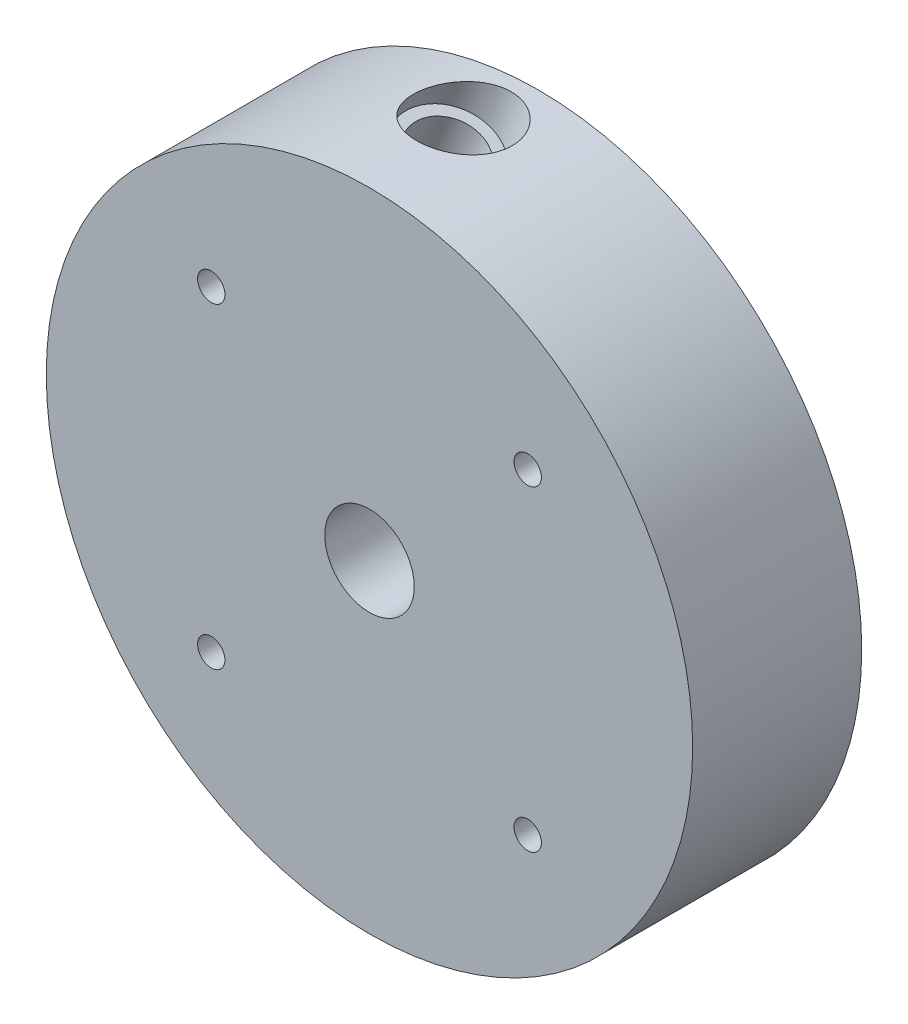
from build123d import *

# Parameters (mm, degrees)
SKETCH3_R          = 65
SKETCH3_R_2        = 2.75
EXTRUDE1_DEPTH     = 34
CUT_EXTRUDE2_DEPTH = 20
SKETCH22_R         = 6.8
CUT_EXTRUDE3_DEPTH = 53.960179098
SKETCH26_R         = 9
CUT_EXTRUDE4_DEPTH = 35.0000001
SKETCH27_R         = 9
CUT_EXTRUDE5_DEPTH = 36.160179098


with BuildPart() as part:
    # Sketch3 → Extrude1 (new body)
    with BuildSketch(Plane.XY):
        Circle(SKETCH3_R)
        with Locations((31.819805153, -31.819805153)):
            Circle(SKETCH3_R_2, mode=Mode.SUBTRACT)
        with Locations((-31.819805153, -31.819805153)):
            Circle(SKETCH3_R_2, mode=Mode.SUBTRACT)
        with Locations((31.819805153, 31.819805153)):
            Circle(SKETCH3_R_2, mode=Mode.SUBTRACT)
        with Locations((-31.819805153, 31.819805153)):
            Circle(SKETCH3_R_2, mode=Mode.SUBTRACT)
    extrude(amount=EXTRUDE1_DEPTH)

    # Sketch3_6 → Cut-Extrude2 (cut)
    with BuildSketch(Plane.XY):
        with BuildLine():
            Line((-20.421328258, 43.144950309), (-27.237880936, 26.740610009))
            ThreePointArc((-27.237880936, 26.740610009), (-28.54324707, 23.999538948), (-30.118972052, 21.404439318))
            add(Edge.make_bspline(
                [(-8.411618966, 31.392589354), (-6.594986557, 31.927343906), (-4.727596656, 32.304011663), (-0.947579394, 32.726950043), (0.964989801, 32.773208373), (4.777108777, 32.531081057), (6.676598891, 32.242693441), (10.404207822, 31.337263886), (12.232267294, 30.720230446), (15.760360448, 29.173637758), (17.460336939, 28.244097303), (20.679062247, 26.098347596), (22.197757805, 24.882166939), (25.005835643, 22.198009273), (26.295170268, 20.730069861), (28.60307704, 17.585286262), (29.621608652, 15.90848759), (31.354425209, 12.395644964), (32.068678043, 10.559653108), (33.168512452, 6.783381836), (33.554071399, 4.84315955), (33.981977998, 0.91703866), (34.024313279, -1.068799499), (33.761644813, -5.025657895), (33.456639413, -6.996616206), (32.505786005, -10.863180522), (31.859947203, -12.758725015), (30.244434466, -16.415746217), (29.274780398, -18.177163724), (27.038718465, -21.510852538), (25.772340603, -23.083068793), (22.979235835, -25.988634722), (21.452548225, -27.321935222), (18.18350905, -29.706877352), (16.441204938, -30.758477245), (12.792592203, -32.545523582), (10.886337796, -33.28093707), (6.966927518, -34.410539179), (4.95383101, -34.804704707), (0.881572969, -35.237007362), (-1.17752584, -35.275132047), (-5.279057127, -34.991353155), (-7.321425423, -34.669448256), (-11.326780574, -33.672621975), (-13.289703752, -32.997710517), (-17.075395447, -31.312765708), (-18.898102754, -30.302753307), (-22.346412369, -27.975919739), (-23.971957836, -26.659129989), (-26.974594454, -23.756685335), (-28.351634915, -22.171071432), (-30.813133029, -18.777462502), (-31.89754775, -16.969516871), (-33.738297145, -13.184908034), (-34.494598024, -11.208301165), (-35.653409825, -7.145620969), (-36.055897198, -5.05960924), (-36.492023631, -0.841182208), (-36.525650191, 1.29116809), (-36.220191785, 5.537304064), (-35.881105833, 7.651023301), (-34.837758132, 11.795003117), (-34.13350703, 13.825197856), (-32.378618873, 17.739300975), (-31.328003859, 19.623146143), (-30.118972052, 21.404439318)],
                knots=[0, 0, 0, 0, 0.03125, 0.03125, 0.0625, 0.0625, 0.09375, 0.09375, 0.125, 0.125, 0.15625, 0.15625, 0.1875, 0.1875, 0.21875, 0.21875, 0.25, 0.25, 0.28125, 0.28125, 0.3125, 0.3125, 0.34375, 0.34375, 0.375, 0.375, 0.40625, 0.40625, 0.4375, 0.4375, 0.46875, 0.46875, 0.5, 0.5, 0.53125, 0.53125, 0.5625, 0.5625, 0.59375, 0.59375, 0.625, 0.625, 0.65625, 0.65625, 0.6875, 0.6875, 0.71875, 0.71875, 0.75, 0.75, 0.78125, 0.78125, 0.8125, 0.8125, 0.84375, 0.84375, 0.875, 0.875, 0.90625, 0.90625, 0.9375, 0.9375, 0.96875, 0.96875, 1, 1, 1, 1], degree=3))
            Line((-8.411618966, 31.392589354), (-6.015539335, 37.158862647))
            Line((-6.015539335, 37.158862647), (-20.421328258, 43.144950309))
        make_face()
    extrude(amount=CUT_EXTRUDE2_DEPTH, mode=Mode.SUBTRACT)

    # Sketch22 → Cut-Extrude3 (cut, through all)
    with BuildSketch(Plane(origin=(12.281446339, 29.555852442, 0), x_dir=(-0.923448008, 0.383723568, 0), z_dir=(0.383723568, 0.923448008, 0))):
        with Locations(Location((27.613769175, 12, 0), (0, 0, 180))):  # turned: the seam where the file's is
            Circle(SKETCH22_R)
    extrude(amount=CUT_EXTRUDE3_DEPTH, mode=Mode.SUBTRACT)

    # Sketch26 → Cut-Extrude4 (cut, through all)
    with BuildSketch(Plane.XY):
        Circle(SKETCH26_R)
    extrude(amount=CUT_EXTRUDE4_DEPTH, mode=Mode.SUBTRACT)

    # Sketch27 → Cut-Extrude5 (cut, through all)
    with BuildSketch(Plane(origin=(19.11172585, 45.993226983, 0), x_dir=(0.923448008, -0.383723568, 0), z_dir=(-0.383723568, -0.923448008, 0))):
        with Locations((-27.613769175, 12)):
            Circle(SKETCH27_R)
    extrude(amount=-CUT_EXTRUDE5_DEPTH, mode=Mode.SUBTRACT)


solid = part.part
